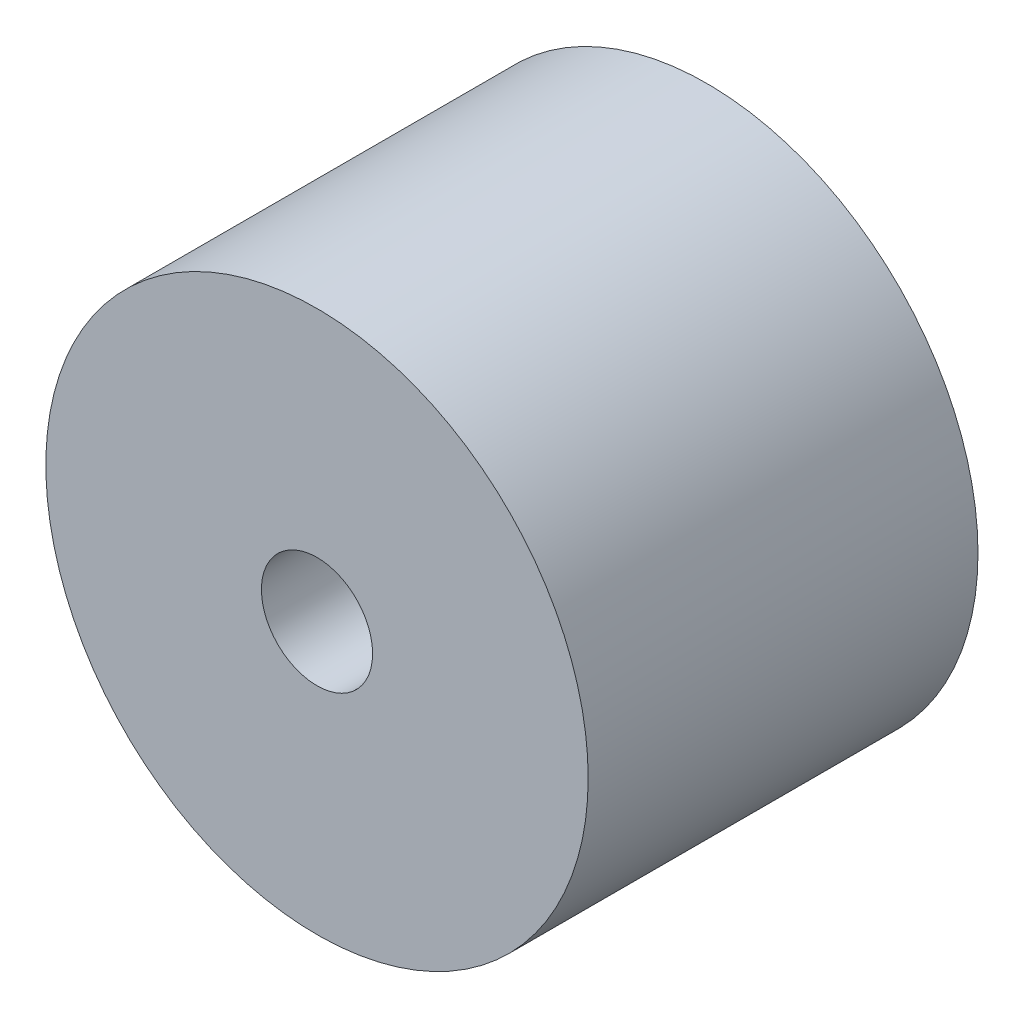
from build123d import *

# Parameters (mm, degrees)
SKETCH1_R           = 20
BOSS_EXTRUDE1_DEPTH = 28.75
SKETCH3_R           = 4.1
CUT_EXTRUDE1_DEPTH  = 41.330664512


with BuildPart() as part:
    # Sketch1 → Boss-Extrude1 (new body)
    with BuildSketch(Plane.XY):
        Circle(SKETCH1_R)
    extrude(amount=BOSS_EXTRUDE1_DEPTH)

    # Sketch3 → Cut-Extrude1 (cut, through all)
    with BuildSketch(Plane.XY.offset(28.75)):
        Circle(SKETCH3_R)
    extrude(amount=-CUT_EXTRUDE1_DEPTH, mode=Mode.SUBTRACT)


solid = part.part
